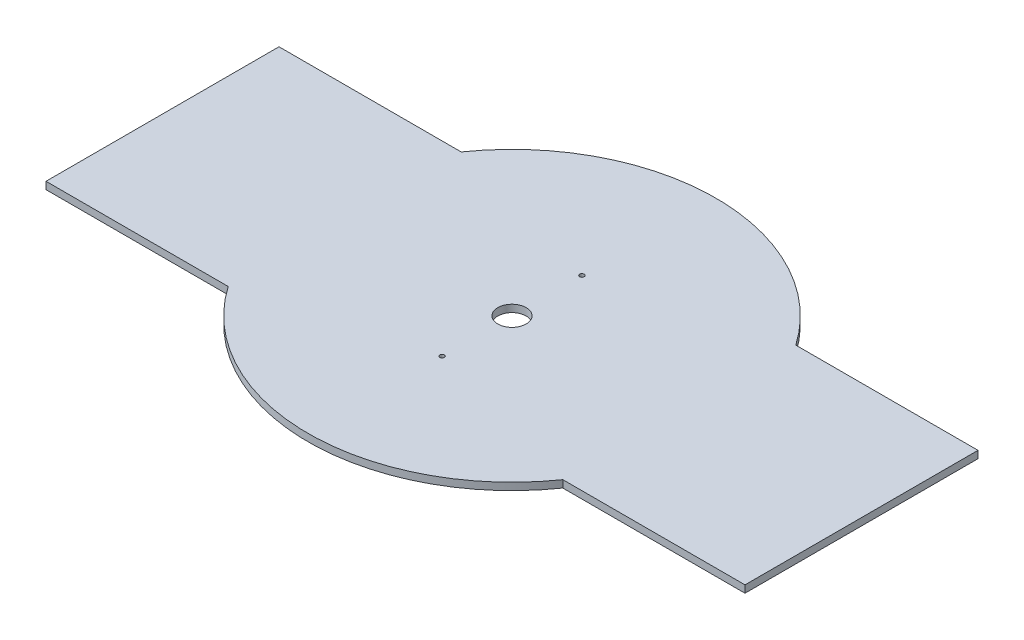
from build123d import *

# Parameters (mm, degrees)
SKETCH2_R           = 0.775
SKETCH2_R_2         = 4.875
BOSS_EXTRUDE1_DEPTH = 2.5


with BuildPart() as part:
    # Sketch2 → Boss-Extrude1 (new body)
    with BuildSketch(Plane(origin=(0, 0, 0), x_dir=(1, 0, 0), z_dir=(0, 1, 0))):
        with BuildLine():
            Line((-57.445626465, 40), (-120, 40))
            Line((-120, 40), (-120, -40))
            Line((-120, -40), (-57.445626465, -40))
            ThreePointArc((-57.445626465, -40), (0, -70), (57.445626465, -40))
            Line((57.445626465, -40), (120, -40))
            Line((120, -40), (120, 40))
            Line((120, 40), (57.445626465, 40))
            ThreePointArc((57.445626465, 40), (0, 70), (-57.445626465, 40))
        make_face()
        with Locations((0, 24)):
            Circle(SKETCH2_R, mode=Mode.SUBTRACT)
        with Locations((0, -24)):
            Circle(SKETCH2_R, mode=Mode.SUBTRACT)
        Circle(SKETCH2_R_2, mode=Mode.SUBTRACT)
    extrude(amount=BOSS_EXTRUDE1_DEPTH)


solid = part.part
